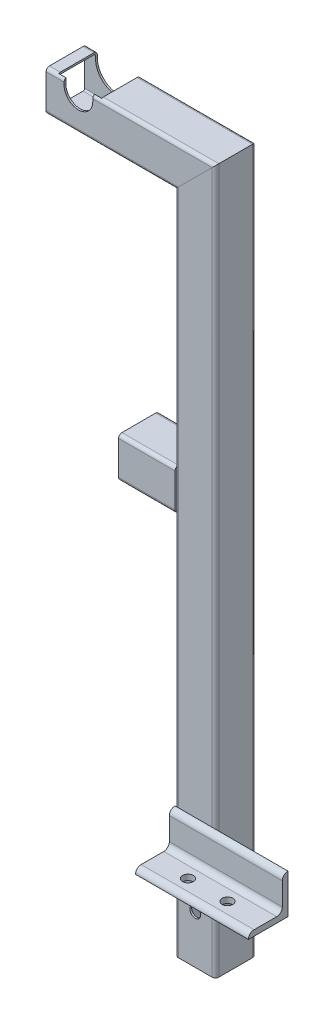
from build123d import *

# Parameters (mm, degrees)
STRUCTURAL_MEMBERMAIN_DEPTH                   = 1
STRUCTURAL_MEMBERMAIN_DEPTH_BACK              = 80
STRUCTURAL_MEMBERMAIN_2_DEPTH                 = 553.314422766
STRUCTURAL_MEMBERMAIN_3_DEPTH                 = 158.414422766
STRUCTURAL_MEMBERMAIN_4_DEPTH                 = 68.9
CUT_EXTRUDETOPRAILGUIDE_DEPTH                 = 664.35854476
CUT_EXTRUDETOPRAILGUIDE_DEPTH_BACK            = 664.35854476
STRUCTURAL_MEMBERANGLE_DEPTH                  = 100
SKETCH15_R                                    = 4.7625
CUT_EXTRUDEMOUNTINGHOLES_DEPTH                = 704.811859737
CUT_EXTRUDEENLARGERAILGUIDE_DEPTH             = 704.811859737
CUT_EXTRUDEENLARGERAILGUIDE_DIRECTION_2_REACH = 705.812
SKETCH19_R                                    = 4.7625
CUT_EXTRUDE1_DEPTH                            = 703.733494225


with BuildPart() as part:
    # Sketch11 → Structural MemberMain (new, two sides)
    with BuildSketch(Plane(origin=(361.4375, 0, 0), x_dir=(-1, 0, 0), z_dir=(0, 1, 0))) as structural_membermain_sk:
        with BuildLine():
            Line((-14.9, 17.9), (14.9, 17.9))
            ThreePointArc((14.9, 17.9), (17.021320344, 17.021320344), (17.9, 14.9))
            Line((17.9, 14.9), (17.9, -14.9))
            ThreePointArc((17.9, -14.9), (17.021320344, -17.021320344), (14.9, -17.9))
            Line((14.9, -17.9), (-14.9, -17.9))
            ThreePointArc((-14.9, -17.9), (-17.021320344, -17.021320344), (-17.9, -14.9))
            Line((-17.9, -14.9), (-17.9, 14.9))
            ThreePointArc((-17.9, 14.9), (-17.021320344, 17.021320344), (-14.9, 17.9))
        make_face()
        with BuildLine():
            Line((-14.9, 16.3), (14.9, 16.3))
            ThreePointArc((14.9, 16.3), (15.889949494, 15.889949494), (16.3, 14.9))
            Line((16.3, 14.9), (16.3, -14.9))
            ThreePointArc((16.3, -14.9), (15.889949494, -15.889949494), (14.9, -16.3))
            Line((14.9, -16.3), (-14.9, -16.3))
            ThreePointArc((-14.9, -16.3), (-15.889949494, -15.889949494), (-16.3, -14.9))
            Line((-16.3, -14.9), (-16.3, 14.9))
            ThreePointArc((-16.3, 14.9), (-15.889949494, 15.889949494), (-14.9, 16.3))
        make_face(mode=Mode.SUBTRACT)
    extrude(amount=STRUCTURAL_MEMBERMAIN_DEPTH)
    extrude(structural_membermain_sk.sketch, amount=-STRUCTURAL_MEMBERMAIN_DEPTH_BACK)

    # Structural MemberMain mitre 1
    split(bisect_by=Plane(origin=(361.4375, 0, 0), x_dir=(1, 0, 0), z_dir=(0, -1, 0)), keep=Keep.TOP)

    # Sketch19 → Cut-Extrude1 (cut, through all)
    with BuildSketch(Plane.XY.offset(17.9)):
        with Locations((361.4375, -37.5)):
            Circle(SKETCH19_R)
    extrude(amount=-CUT_EXTRUDE1_DEPTH, mode=Mode.SUBTRACT)


with BuildPart() as body_2:
    # Sketch11 on segment 2 (carried to segment 2) → Structural MemberMain 2 (new body)
    with BuildSketch(Plane(origin=(361.4375, -1, 0), x_dir=(-1, 0, 0), z_dir=(0, 1, 0))):
        with BuildLine():
            Line((-14.9, 17.9), (14.9, 17.9))
            ThreePointArc((14.9, 17.9), (17.021320344, 17.021320344), (17.9, 14.9))
            Line((17.9, 14.9), (17.9, -14.9))
            ThreePointArc((17.9, -14.9), (17.021320344, -17.021320344), (14.9, -17.9))
            Line((14.9, -17.9), (-14.9, -17.9))
            ThreePointArc((-14.9, -17.9), (-17.021320344, -17.021320344), (-17.9, -14.9))
            Line((-17.9, -14.9), (-17.9, 14.9))
            ThreePointArc((-17.9, 14.9), (-17.021320344, 17.021320344), (-14.9, 17.9))
        make_face()
        with BuildLine():
            Line((-14.9, 16.3), (14.9, 16.3))
            ThreePointArc((14.9, 16.3), (15.889949494, 15.889949494), (16.3, 14.9))
            Line((16.3, 14.9), (16.3, -14.9))
            ThreePointArc((16.3, -14.9), (15.889949494, -15.889949494), (14.9, -16.3))
            Line((14.9, -16.3), (-14.9, -16.3))
            ThreePointArc((-14.9, -16.3), (-15.889949494, -15.889949494), (-16.3, -14.9))
            Line((-16.3, -14.9), (-16.3, 14.9))
            ThreePointArc((-16.3, 14.9), (-15.889949494, 15.889949494), (-14.9, 16.3))
        make_face(mode=Mode.SUBTRACT)
    extrude(amount=STRUCTURAL_MEMBERMAIN_2_DEPTH)

    # Structural MemberMain 2 mitre 1
    split(bisect_by=Plane(origin=(361.4375, 0, 0), x_dir=(-1, 0, 0), z_dir=(0, 1, 0)), keep=Keep.TOP)

    # Structural MemberMain 2 mitre 2
    split(bisect_by=Plane(origin=(361.4375, 526, 0), x_dir=(0.707106781, 0.707106781, 0), z_dir=(0.707106781, -0.707106781, 0)), keep=Keep.TOP)


with BuildPart() as body_3:
    # Sketch11 on segment 3 (carried to segment 3) → Structural MemberMain 3 (new body)
    with BuildSketch(Plane(origin=(387.751922766, 526, 0), x_dir=(0, -1, 0), z_dir=(-1, 0, 0))):
        with BuildLine():
            Line((-14.9, 17.9), (14.9, 17.9))
            ThreePointArc((14.9, 17.9), (17.021320344, 17.021320344), (17.9, 14.9))
            Line((17.9, 14.9), (17.9, -14.9))
            ThreePointArc((17.9, -14.9), (17.021320344, -17.021320344), (14.9, -17.9))
            Line((14.9, -17.9), (-14.9, -17.9))
            ThreePointArc((-14.9, -17.9), (-17.021320344, -17.021320344), (-17.9, -14.9))
            Line((-17.9, -14.9), (-17.9, 14.9))
            ThreePointArc((-17.9, 14.9), (-17.021320344, 17.021320344), (-14.9, 17.9))
        make_face()
        with BuildLine():
            Line((-14.9, 16.3), (14.9, 16.3))
            ThreePointArc((14.9, 16.3), (15.889949494, 15.889949494), (16.3, 14.9))
            Line((16.3, 14.9), (16.3, -14.9))
            ThreePointArc((16.3, -14.9), (15.889949494, -15.889949494), (14.9, -16.3))
            Line((14.9, -16.3), (-14.9, -16.3))
            ThreePointArc((-14.9, -16.3), (-15.889949494, -15.889949494), (-16.3, -14.9))
            Line((-16.3, -14.9), (-16.3, 14.9))
            ThreePointArc((-16.3, 14.9), (-15.889949494, 15.889949494), (-14.9, 16.3))
        make_face(mode=Mode.SUBTRACT)
    extrude(amount=STRUCTURAL_MEMBERMAIN_3_DEPTH)

    # Structural MemberMain 3 mitre 1
    split(bisect_by=Plane(origin=(361.4375, 526, 0), x_dir=(-0.707106781, -0.707106781, 0), z_dir=(-0.707106781, 0.707106781, 0)), keep=Keep.TOP)

    # Sketch12 → Cut-ExtrudeTopRailGuide (cut, two sides)
    with BuildSketch(Plane.XY) as cut_extrudetoprailguide_sk:
        with BuildLine():
            Line((245.3, 538.7), (245.3, 549.1))
            ThreePointArc((245.3, 549.1), (258, 561.8), (270.7, 549.1))
            Line((270.7, 549.1), (270.7, 538.7))
            ThreePointArc((270.7, 538.7), (258, 526), (245.3, 538.7))
        make_face()
    extrude(amount=CUT_EXTRUDETOPRAILGUIDE_DEPTH, mode=Mode.SUBTRACT)
    extrude(cut_extrudetoprailguide_sk.sketch, amount=-CUT_EXTRUDETOPRAILGUIDE_DEPTH_BACK, mode=Mode.SUBTRACT)

    # Sketch16 → Cut-ExtrudeEnlargeRailGuide (cut)
    with BuildSketch(Plane.XY):
        with BuildLine():
            Line((277.05, 538.7), (277.05, 549.1))
            ThreePointArc((277.05, 549.1), (258, 568.15), (238.95, 549.1))
            Line((238.95, 549.1), (238.95, 538.7))
            ThreePointArc((238.95, 538.7), (258, 519.65), (277.05, 538.7))
        make_face()
    extrude(amount=-CUT_EXTRUDEENLARGERAILGUIDE_DEPTH, mode=Mode.SUBTRACT)

    # Cut-ExtrudeEnlargeRailGuide direction 2: up to this face of the body (flat: up to its plane)
    cut_extrudeenlargerailguide_direction_2_end = Plane(body_3.part.faces().sort_by_distance((298.87879231, 525.884806009, 16.3))[0])
    # Sketch16 → Cut-ExtrudeEnlargeRailGuide direction 2 (cut, up to the picked face)
    with BuildSketch(Plane.XY, mode=Mode.PRIVATE) as cut_extrudeenlargerailguide_direction_2_sk1:
        with BuildLine():
            Line((277.05, 538.7), (277.05, 549.1))
            ThreePointArc((277.05, 549.1), (258, 568.15), (238.95, 549.1))
            Line((238.95, 549.1), (238.95, 538.7))
            ThreePointArc((238.95, 538.7), (258, 519.65), (277.05, 538.7))
        make_face()
    cut_extrudeenlargerailguide_direction_2_tool1 = split(extrude(cut_extrudeenlargerailguide_direction_2_sk1.sketch, amount=CUT_EXTRUDEENLARGERAILGUIDE_DIRECTION_2_REACH, mode=Mode.PRIVATE), bisect_by=cut_extrudeenlargerailguide_direction_2_end, keep=Keep.BOTH, mode=Mode.PRIVATE)
    add(cut_extrudeenlargerailguide_direction_2_tool1.solids().sort_by(Axis((258, 543.9, 0), (0, 0, 1)))[0], mode=Mode.SUBTRACT)


with BuildPart() as body_4:
    # Sketch11 on segment 4 (carried to segment 4) → Structural MemberMain 4 (new body)
    with BuildSketch(Plane(origin=(293.5375, 276.9, 0), x_dir=(0, 1, 0), z_dir=(1, 0, 0))):
        with BuildLine():
            Line((-14.9, 17.9), (14.9, 17.9))
            ThreePointArc((14.9, 17.9), (17.021320344, 17.021320344), (17.9, 14.9))
            Line((17.9, 14.9), (17.9, -14.9))
            ThreePointArc((17.9, -14.9), (17.021320344, -17.021320344), (14.9, -17.9))
            Line((14.9, -17.9), (-14.9, -17.9))
            ThreePointArc((-14.9, -17.9), (-17.021320344, -17.021320344), (-17.9, -14.9))
            Line((-17.9, -14.9), (-17.9, 14.9))
            ThreePointArc((-17.9, 14.9), (-17.021320344, 17.021320344), (-14.9, 17.9))
        make_face()
        with BuildLine():
            Line((-14.9, 16.3), (14.9, 16.3))
            ThreePointArc((14.9, 16.3), (15.889949494, 15.889949494), (16.3, 14.9))
            Line((16.3, 14.9), (16.3, -14.9))
            ThreePointArc((16.3, -14.9), (15.889949494, -15.889949494), (14.9, -16.3))
            Line((14.9, -16.3), (-14.9, -16.3))
            ThreePointArc((-14.9, -16.3), (-15.889949494, -15.889949494), (-16.3, -14.9))
            Line((-16.3, -14.9), (-16.3, 14.9))
            ThreePointArc((-16.3, 14.9), (-15.889949494, 15.889949494), (-14.9, 16.3))
        make_face(mode=Mode.SUBTRACT)
    extrude(amount=STRUCTURAL_MEMBERMAIN_4_DEPTH)

    # Structural MemberMain 4 mitre 1
    split(bisect_by=Plane(origin=(343.5375, 276.9, 0), x_dir=(0, -1, 0), z_dir=(-1, 0, 0)), keep=Keep.TOP)


with BuildPart() as body_5:
    # Sketch14 → Structural MemberAngle (new body)
    with BuildSketch(Plane(origin=(343.5375, 0, 17.9), x_dir=(0, 1, 0), z_dir=(1, 0, 0))):
        with BuildLine():
            Line((0, 0), (0, 35))
            ThreePointArc((0, 35), (3.535533906, 33.535533906), (5, 30))
            Line((5, 30), (5, 10))
            ThreePointArc((5, 10), (6.464466094, 6.464466094), (10, 5))
            Line((10, 5), (30, 5))
            ThreePointArc((30, 5), (33.535533906, 3.535533906), (35, 0))
            Line((35, 0), (0, 0))
        make_face()
    extrude(amount=STRUCTURAL_MEMBERANGLE_DEPTH)

    # Sketch15 → Cut-ExtrudeMountingHoles (cut, through all)
    with BuildSketch(Plane(origin=(0, 0, 0), x_dir=(1, 0, 0), z_dir=(0, 1, 0))):
        with Locations(Location((375, -37.9, 0), (0, 0, 90))):
            Circle(SKETCH15_R)
        with Locations(Location((410, -37.9, 0), (0, 0, 90))):
            Circle(SKETCH15_R)
    extrude(amount=CUT_EXTRUDEMOUNTINGHOLES_DEPTH, mode=Mode.SUBTRACT)


solid = Compound([part.part, body_2.part, body_3.part, body_4.part, body_5.part])
